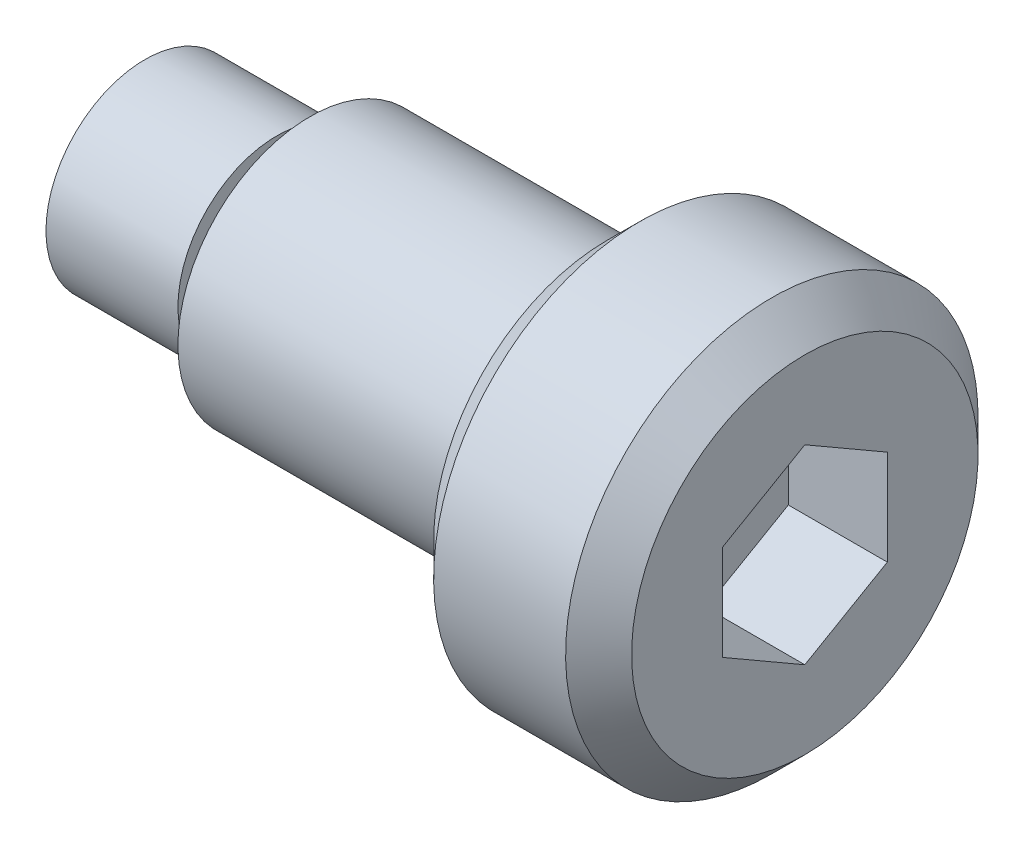
from build123d import *

# Parameters (mm, degrees)
CUT_EXTRUDE1_DEPTH      = 1
CUT_EXTRUDE1_DEPTH_BACK = 6


with BuildPart() as part:
    # Sketch1 → Revolve1 (revolve)
    with BuildSketch(Plane.XY):
        Polygon((-20, 0), (-20, 6), (-12, 6), (-12, 5), (-10, 5), (-10, 8), (8, 8), (8, 10.5), (10, 12.5), (18, 12.5), (20, 10.5), (20, 0), align=None)
    revolve(axis=Axis((-20, 0, 0), (1, 0, 0)))

    # Sketch2 → Cut-Extrude1 (cut, two sides)
    with BuildSketch(Plane(origin=(20, 0, 0), x_dir=(0, 0, -1), z_dir=(1, 0, 0))) as cut_extrude1_sk:
        Polygon((0, 5.773502692), (-5, 2.886751346), (-5, -2.886751346), (0, -5.773502692), (5, -2.886751346), (5, 2.886751346), align=None)
    extrude(amount=CUT_EXTRUDE1_DEPTH, mode=Mode.SUBTRACT)
    extrude(cut_extrude1_sk.sketch, amount=-CUT_EXTRUDE1_DEPTH_BACK, mode=Mode.SUBTRACT)


solid = part.part
